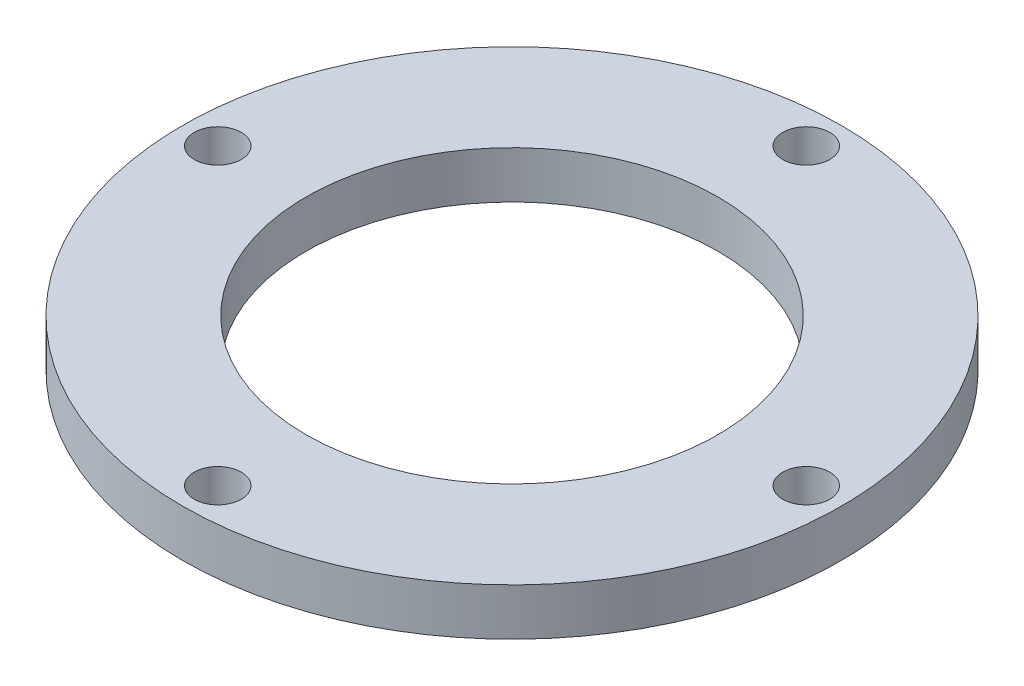
from build123d import *

# Parameters (mm, degrees)
ESQUISSE1_R        = 56
ESQUISSE1_R_2      = 35
ESQUISSE1_R_3      = 4
BOSS_EXTRU_1_DEPTH = 8


with BuildPart() as part:
    # Esquisse1 → Boss.-Extru.1 (new body)
    with BuildSketch(Plane(origin=(0, 0, 0), x_dir=(1, 0, 0), z_dir=(0, 1, 0))):
        with Locations(Location((0, 0, 0), (0, 0, 270))):  # turned: the seam where the file's is
            Circle(ESQUISSE1_R)
        with Locations(Location((0, 0, 0), (0, 0, 270))):  # turned: the seam where the file's is
            Circle(ESQUISSE1_R_2, mode=Mode.SUBTRACT)
        with Locations(Location((0, 50, 0), (0, 0, 270))):  # turned: the seam where the file's is
            Circle(ESQUISSE1_R_3, mode=Mode.SUBTRACT)
        with Locations(Location((50, 0, 0), (0, 0, 270))):  # turned: the seam where the file's is
            Circle(ESQUISSE1_R_3, mode=Mode.SUBTRACT)
        with Locations(Location((0, -50, 0), (0, 0, 270))):  # turned: the seam where the file's is
            Circle(ESQUISSE1_R_3, mode=Mode.SUBTRACT)
        with Locations(Location((-50, 0, 0), (0, 0, 270))):  # turned: the seam where the file's is
            Circle(ESQUISSE1_R_3, mode=Mode.SUBTRACT)
    extrude(amount=BOSS_EXTRU_1_DEPTH)


solid = part.part
